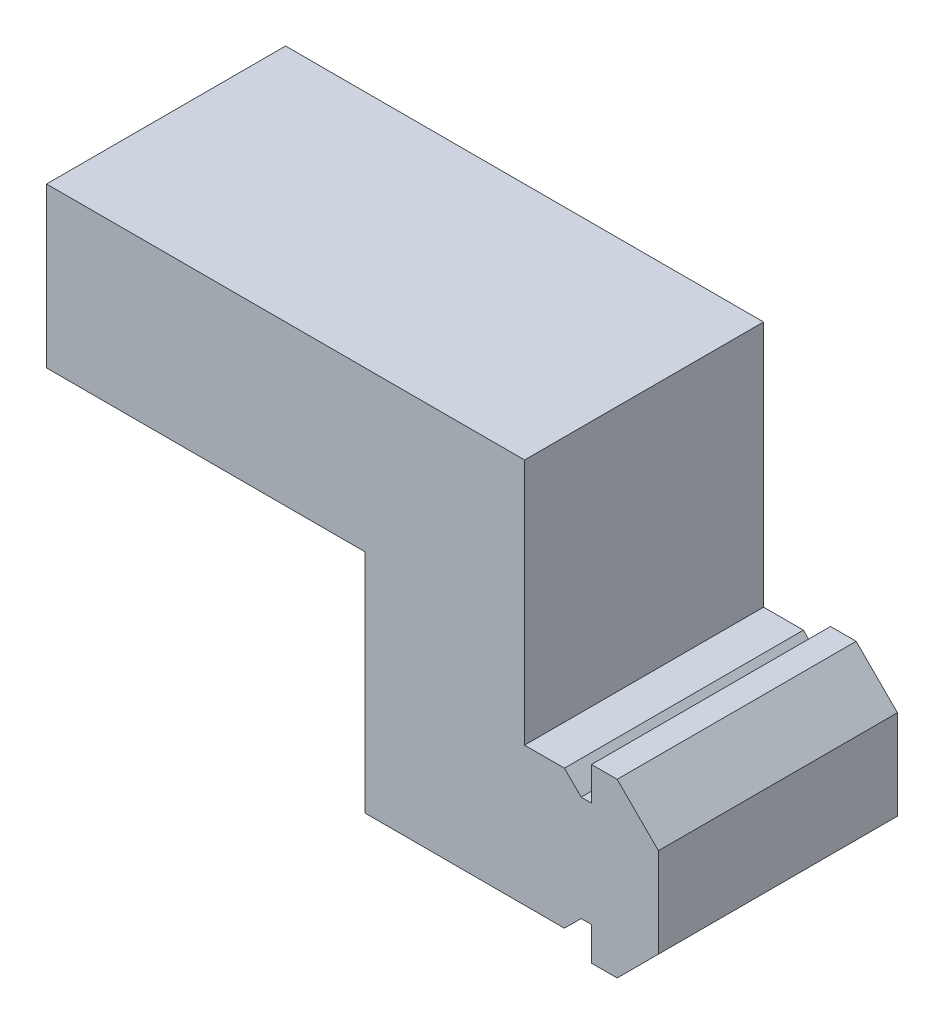
from build123d import *

# Parameters (mm, degrees)
BOSS_EXTRUDE1_DEPTH = 15
SKETCH2_W           = 15
SKETCH2_H           = 8.7
BOSS_EXTRUDE2_DEPTH = 12.5
SKETCH3_W           = 10
SKETCH3_H           = 15
BOSS_EXTRUDE3_DEPTH = 15.5
SKETCH5_W           = 15
SKETCH5_H           = 10
BOSS_EXTRUDE4_DEPTH = 20


with BuildPart() as part:
    # Sketch1 → Boss-Extrude1 (new body)
    with BuildSketch(Plane.XY):
        Polygon((-3.665803919, -0.605497889), (-3.665803919, 8.094502111), (-2.615803919, 7.044502111), (-1.965803919, 7.044502111), (-1.965803919, 9.144502111), (-0.354656646, 9.144502111), (2.234196081, 6.555649384), (2.234196081, 0.933354838), (-0.354656646, -1.655497889), (-1.965803919, -1.655497889), (-1.965803919, 0.444502111), (-2.615803919, 0.444502111), align=None)
    extrude(amount=BOSS_EXTRUDE1_DEPTH)

    # Sketch2 → Boss-Extrude2 (add)
    with BuildSketch(Plane.ZY.offset(3.665803919)):
        with Locations((7.5, 3.744502111)):
            Rectangle(SKETCH2_W, SKETCH2_H)
    extrude(amount=BOSS_EXTRUDE2_DEPTH)

    # Sketch3 → Boss-Extrude3 (add)
    with BuildSketch(Plane(origin=(0, 8.094502111, 0), x_dir=(1, 0, 0), z_dir=(0, 1, 0))):
        with Locations((-11.165803919, -7.5)):
            Rectangle(SKETCH3_W, SKETCH3_H)
    extrude(amount=BOSS_EXTRUDE3_DEPTH)

    # Sketch5 → Boss-Extrude4 (add)
    with BuildSketch(Plane.ZY.offset(16.165803919)):
        with Locations((7.5, 18.594502111)):
            Rectangle(SKETCH5_W, SKETCH5_H)
    extrude(amount=BOSS_EXTRUDE4_DEPTH)


solid = part.part
